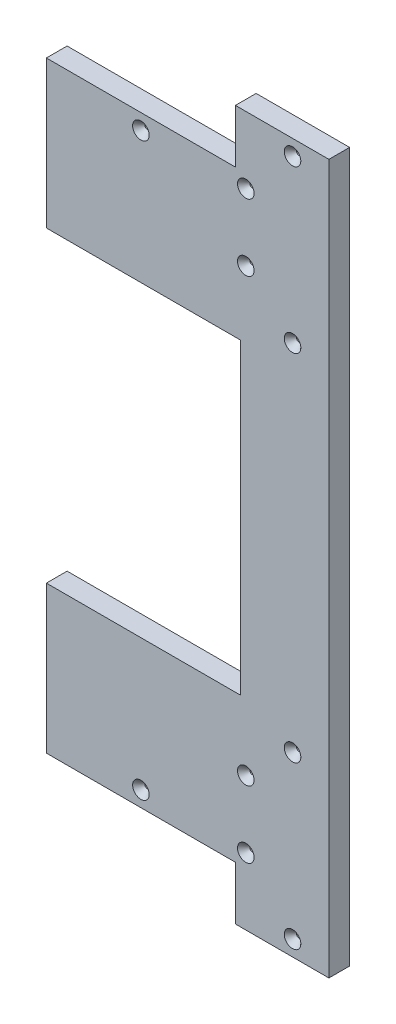
from build123d import *

# Parameters (mm, degrees)
SKETCH1_W           = 198.582793441
SKETCH1_H           = 434.599999988
BOSS_EXTRUDE1_DEPTH = 12.7
CUT_EXTRUDE1_REACH  = 14.7
SKETCH2_W           = 141.287862113
SKETCH2_H           = 32.775
CUT_EXTRUDE2_REACH  = 14.7
HOLE1_D             = 3.175
HOLE1_DEPTH         = 38.1
HOLE1_CSINK_D       = 10.16
HOLE1_CSINK_ANGLE   = 82
HOLE1_TIP           = 0.953866233


with BuildPart() as part:
    # Sketch1 → Boss-Extrude1 (new body)
    with BuildSketch(Plane.XY):
        with Locations((17.439596016, 0)):
            Rectangle(SKETCH1_W, SKETCH1_H)
    extrude(amount=BOSS_EXTRUDE1_DEPTH)

    # Sketch2 → Cut-Extrude1 (cut, up to next)
    with BuildSketch(Plane(origin=(0, 0, 0), x_dir=(-1, 0, 0), z_dir=(0, 0, -1)), mode=Mode.PRIVATE) as cut_extrude1_sk1:
        with Locations((11.207869649, 200.912499994)):
            Rectangle(SKETCH2_W, SKETCH2_H)
    cut_extrude1_tool1 = extrude(cut_extrude1_sk1.sketch, amount=-CUT_EXTRUDE1_REACH, mode=Mode.PRIVATE) & part.part
    add(cut_extrude1_tool1.solids().sort_by_distance((-11.20787, 200.9125, 0))[0], mode=Mode.SUBTRACT)
    # Sketch2 → Cut-Extrude1 (cut, up to next)
    with BuildSketch(Plane(origin=(0, 0, 0), x_dir=(-1, 0, 0), z_dir=(0, 0, -1)), mode=Mode.PRIVATE) as cut_extrude1_sk2:
        with Locations((11.207869649, -200.912499994)):
            Rectangle(SKETCH2_W, SKETCH2_H)
    cut_extrude1_tool2 = extrude(cut_extrude1_sk2.sketch, amount=-CUT_EXTRUDE1_REACH, mode=Mode.PRIVATE) & part.part
    add(cut_extrude1_tool2.solids().sort_by_distance((-11.20787, -200.9125, 0))[0], mode=Mode.SUBTRACT)

    # Sketch3 → Cut-Extrude2 (cut, up to next)
    with BuildSketch(Plane.XY.offset(12.7), mode=Mode.PRIVATE) as cut_extrude2_sk1:
        Polygon((62.611061408, 94.249999997), (-56.451800705, 94.249999997), (-56.451800705, 184.524999994), (-81.851800705, 184.524999994), (-81.851800705, 94.249999997), (-85.026800705, 94.249999997), (-85.026800705, -94.249999997), (-81.851800705, -94.249999997), (-81.851800705, -184.524999994), (-56.451800705, -184.524999994), (-56.451800705, -94.249999997), (62.611061408, -94.249999997), align=None)
    cut_extrude2_tool1 = extrude(cut_extrude2_sk1.sketch, amount=-CUT_EXTRUDE2_REACH, mode=Mode.PRIVATE) & part.part
    add(cut_extrude2_tool1.solids().sort_by_distance((-19.405412, 0, 12.7))[0], mode=Mode.SUBTRACT)

    # Hole1
    with Locations(Plane(origin=(449.828463103, 0, 12.7), x_dir=(0, 1, 0), z_dir=(0, 0, 1))):
        with Locations((-108.649999997, 355.39493603), (108.649999997, 355.39493603), (207.774999994, 355.39493603), (174.999999994, 448.336332751), (135.266666663, 384.042401694), (176.283333328, 384.042401694), (-174.999999994, 448.336332751), (-135.266666663, 384.042401694), (-176.283333328, 384.042401694), (-207.774999994, 355.39493603)):
            CounterSinkHole(HOLE1_D / 2, HOLE1_CSINK_D / 2, depth=HOLE1_DEPTH, counter_sink_angle=HOLE1_CSINK_ANGLE)
            with Locations((0, 0, -(HOLE1_DEPTH + HOLE1_TIP / 2))):  # 118° drill point
                Cone(0, HOLE1_D / 2, HOLE1_TIP, mode=Mode.SUBTRACT)


solid = part.part
